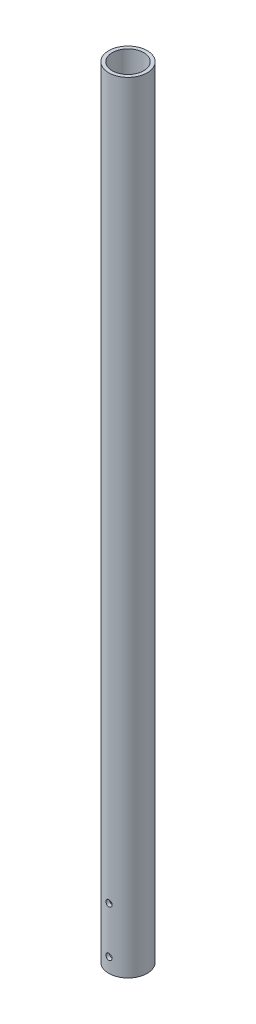
from build123d import *

# Parameters (mm, degrees)
SKETCH1_R               = 21.082
SKETCH1_R_2             = 17.272
BOSS_EXTRUDE1_DEPTH     = 855.6625
F_1_4_CLEARANCE_HOLE1_D = 6.7564


with BuildPart() as part:
    # Sketch1 → Boss-Extrude1 (new body)
    with BuildSketch(Plane(origin=(0, 0, 0), x_dir=(1, 0, 0), z_dir=(0, 1, 0))):
        Circle(SKETCH1_R)
        Circle(SKETCH1_R_2, mode=Mode.SUBTRACT)
    extrude(amount=BOSS_EXTRUDE1_DEPTH)

    # 1/4 Clearance Hole1 (through all)
    with Locations(Plane.XY.offset(21.082)):
        with Locations((0, 15.875), (0, 66.675)):
            Hole(F_1_4_CLEARANCE_HOLE1_D / 2)


solid = part.part
